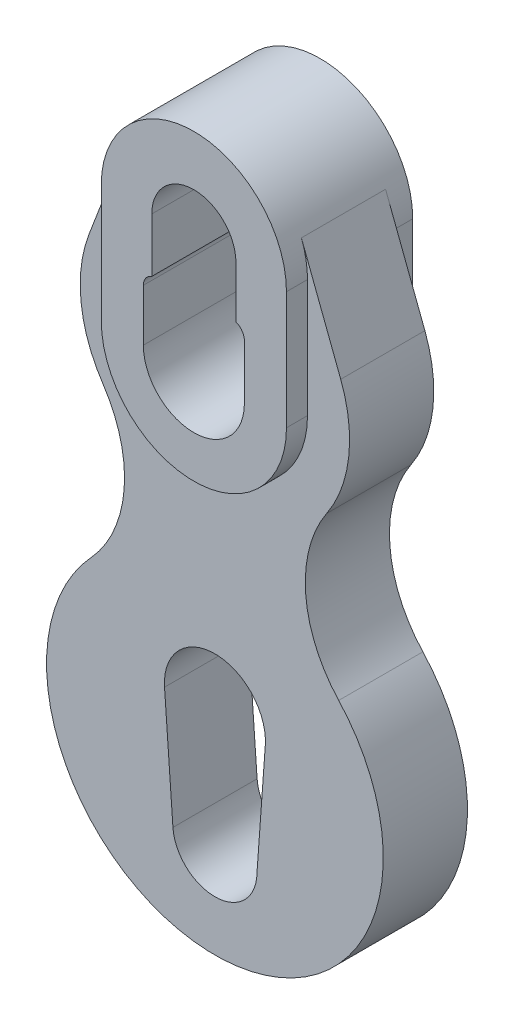
from build123d import *

# Parameters (mm, degrees)
BOSS_EXTRUDE1_DEPTH = 15
BOSS_EXTRUDE3_DEPTH = 10


with BuildPart() as part:
    # Sketch1 → Boss-Extrude1 (new, symmetric)
    with BuildSketch(Plane.XY):
        with BuildLine():
            Line((22, 82), (22, 110))
            ThreePointArc((22, 110), (21.634233178, 113.994991212), (20.54909502, 117.857142857))
            ThreePointArc((20.54909502, 117.857142857), (0, 132), (-20.54909502, 117.857142857))
            ThreePointArc((-20.54909502, 117.857142857), (-21.634233178, 113.994991212), (-22, 110))
            Line((-22, 110), (-22, 82))
            ThreePointArc((-22, 82), (0, 60), (22, 82))
        make_face()
        with BuildLine():
            ThreePointArc((-10, 110), (0, 120), (10, 110))
            Line((10, 110), (10, 97.763084363))
            ThreePointArc((10, 97.763084363), (11.449489743, 96.666708046), (12, 94.934657238))
            Line((12, 94.934657238), (12, 82))
            ThreePointArc((12, 82), (0, 70), (-12, 82))
            Line((-12, 82), (-12, 94.322221654))
            ThreePointArc((-12, 94.322221654), (-11.449489743, 96.054272461), (-10, 97.150648779))
            Line((-10, 97.150648779), (-10, 110))
        make_face(mode=Mode.SUBTRACT)
    extrude(amount=BOSS_EXTRUDE1_DEPTH, both=True)

    # Sketch1_4 → Boss-Extrude3 (add, symmetric)
    with BuildSketch(Plane.XY):
        with BuildLine():
            ThreePointArc((20.54909502, 117.857142857), (21.634233178, 113.994991212), (22, 110))
            Line((22, 110), (22, 82))
            ThreePointArc((22, 82), (0, 60), (-22, 82))
            Line((-22, 82), (-22, 110))
            ThreePointArc((-22, 110), (-21.634233178, 113.994991212), (-20.54909502, 117.857142857))
            Line((-20.54909502, 117.857142857), (-29.889592756, 93.428571429))
            ThreePointArc((-29.889592756, 93.428571429), (-31.795758241, 78.390324411), (-26.567056796, 64.162077105))
            ThreePointArc((-26.567056796, 64.162077105), (-21.561800954, 45.141212789), (-29.413527167, 27.108013937))
            ThreePointArc((-29.413527167, 27.108013937), (0, -40), (29.413527167, 27.108013937))
            ThreePointArc((29.413527167, 27.108013937), (21.561800954, 45.141212789), (26.567056796, 64.162077105))
            ThreePointArc((26.567056796, 64.162077105), (31.795758241, 78.390324411), (29.889592756, 93.428571429))
            Line((29.889592756, 93.428571429), (20.54909502, 117.857142857))
        make_face()
        with BuildLine():
            Line((11.968538667, 9.131620953), (10, -18))
            ThreePointArc((10, -18), (0.357371137, -27.993612253), (-9.974457174, -18.714285714))
            Line((-9.974457174, -18.714285714), (-11.969348609, 9.142857143))
            ThreePointArc((-11.969348609, 9.142857143), (0.005632672, 21.999998678), (11.968538667, 9.131620953))
        make_face(mode=Mode.SUBTRACT)
    extrude(amount=BOSS_EXTRUDE3_DEPTH, both=True)


solid = part.part
